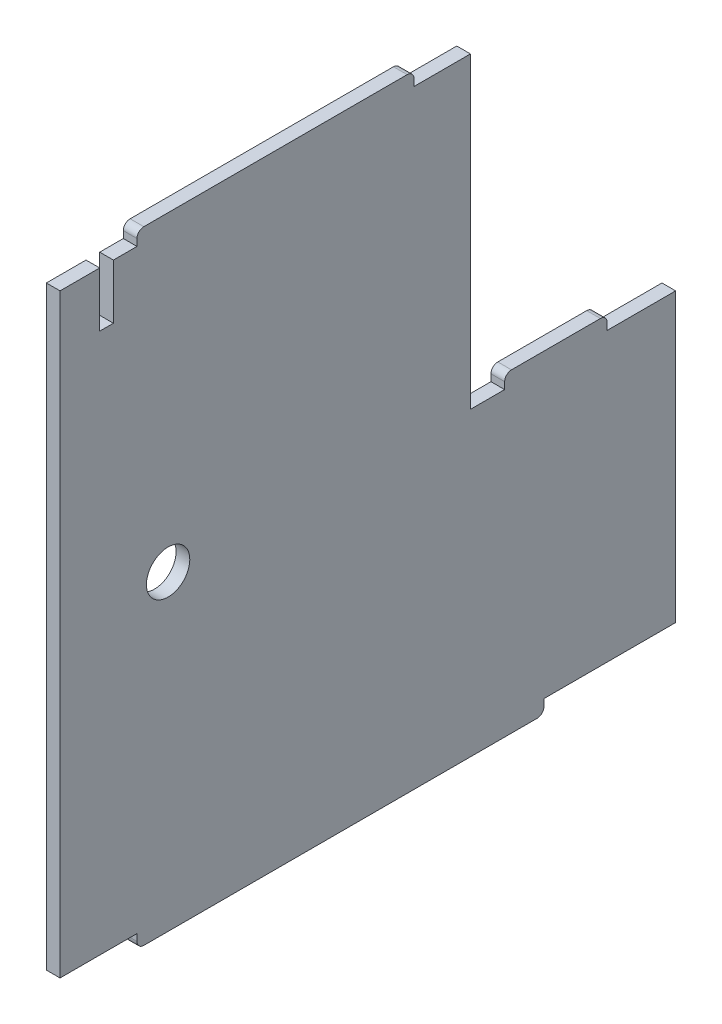
from build123d import *

# Parameters (mm, degrees)
SKETCH2_R           = 3.17
BOSS_EXTRUDE1_DEPTH = 2


with BuildPart() as part:
    # Sketch2 → Boss-Extrude1 (new body)
    with BuildSketch(Plane(origin=(0, 0, 0), x_dir=(0, 0, -1), z_dir=(1, 0, 0))):
        with BuildLine():
            Line((44.752383591, -64.243785516), (44.752383591, -22.243785516))
            Line((44.752383591, -22.243785516), (34.752383591, -22.243785516))
            Line((34.752383591, -22.243785516), (34.752383591, -21.243785516))
            ThreePointArc((34.752383591, -21.243785516), (34.459490372, -20.536678734), (33.752383591, -20.243785516))
            Line((33.752383591, -20.243785516), (20.752383591, -20.243785516))
            ThreePointArc((20.752383591, -20.243785516), (20.045276809, -20.536678734), (19.752383591, -21.243785516))
            Line((19.752383591, -21.243785516), (19.752383591, -22.243785516))
            Line((19.752383591, -22.243785516), (14.752383591, -22.243785516))
            Line((14.752383591, -22.243785516), (14.752383591, 22.756214484))
            Line((14.752383591, 22.756214484), (6.501874719, 22.756214484))
            Line((6.501874719, 22.756214484), (6.501874719, 23.756214484))
            ThreePointArc((6.501874719, 23.756214484), (6.2089815, 24.463321266), (5.501874719, 24.756214484))
            Line((5.501874719, 24.756214484), (-32.997107538, 24.756214484))
            ThreePointArc((-32.997107538, 24.756214484), (-33.704214319, 24.463321266), (-33.997107538, 23.756214484))
            Line((-33.997107538, 23.756214484), (-33.997107538, 22.756214484))
            Line((-33.997107538, 22.756214484), (-37.447616409, 22.756214484))
            Line((-37.447616409, 22.756214484), (-37.447616409, 14.756214484))
            Line((-37.447616409, 14.756214484), (-39.447616409, 14.756214484))
            Line((-39.447616409, 14.756214484), (-39.447616409, 22.756214484))
            Line((-39.447616409, 22.756214484), (-45.247616409, 22.756214484))
            Line((-45.247616409, 22.756214484), (-45.247616409, -64.243785516))
            Line((-45.247616409, -64.243785516), (-33.997107538, -64.243785516))
            Line((-33.997107538, -64.243785516), (-33.997107538, -65.243785516))
            ThreePointArc((-33.997107538, -65.243785516), (-33.704214319, -65.950892297), (-32.997107538, -66.243785516))
            Line((-32.997107538, -66.243785516), (24.501874719, -66.243785516))
            ThreePointArc((24.501874719, -66.243785516), (25.2089815, -65.950892297), (25.501874719, -65.243785516))
            Line((25.501874719, -65.243785516), (25.501874719, -64.243785516))
            Line((25.501874719, -64.243785516), (44.752383591, -64.243785516))
        make_face()
        with Locations((-29.447616409, -20.743785516)):
            Circle(SKETCH2_R, mode=Mode.SUBTRACT)
    extrude(amount=BOSS_EXTRUDE1_DEPTH)


solid = part.part
